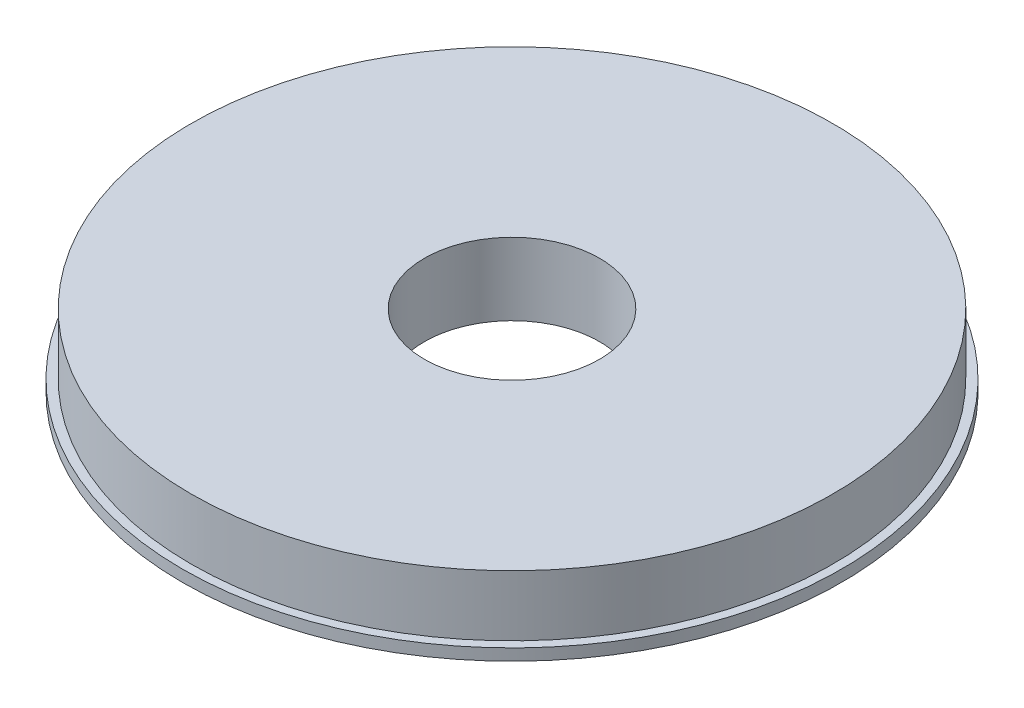
from build123d import *

# Parameters (mm, degrees)
SKETCH1_R           = 55.5
SKETCH1_R_2         = 15.15
BOSS_EXTRUDE1_DEPTH = 12.5
BOSS_EXTRUDE3_START = -12.5
SKETCH3_R           = 57
SKETCH3_R_2         = 55.5
BOSS_EXTRUDE3_DEPTH = 2


with BuildPart() as part:
    # Sketch1 → Boss-Extrude1 (new body)
    with BuildSketch(Plane(origin=(0, 0, 0), x_dir=(1, 0, 0), z_dir=(0, 1, 0))):
        Circle(SKETCH1_R)
        Circle(SKETCH1_R_2, mode=Mode.SUBTRACT)
    extrude(amount=BOSS_EXTRUDE1_DEPTH)

    # Sketch3 → Boss-Extrude3 (add)
    with BuildSketch(Plane(origin=(0, 12.5, 0), x_dir=(1, 0, 0), z_dir=(0, 1, 0)).offset(BOSS_EXTRUDE3_START)):
        Circle(SKETCH3_R)
        Circle(SKETCH3_R_2, mode=Mode.SUBTRACT)
    extrude(amount=BOSS_EXTRUDE3_DEPTH)


solid = part.part
